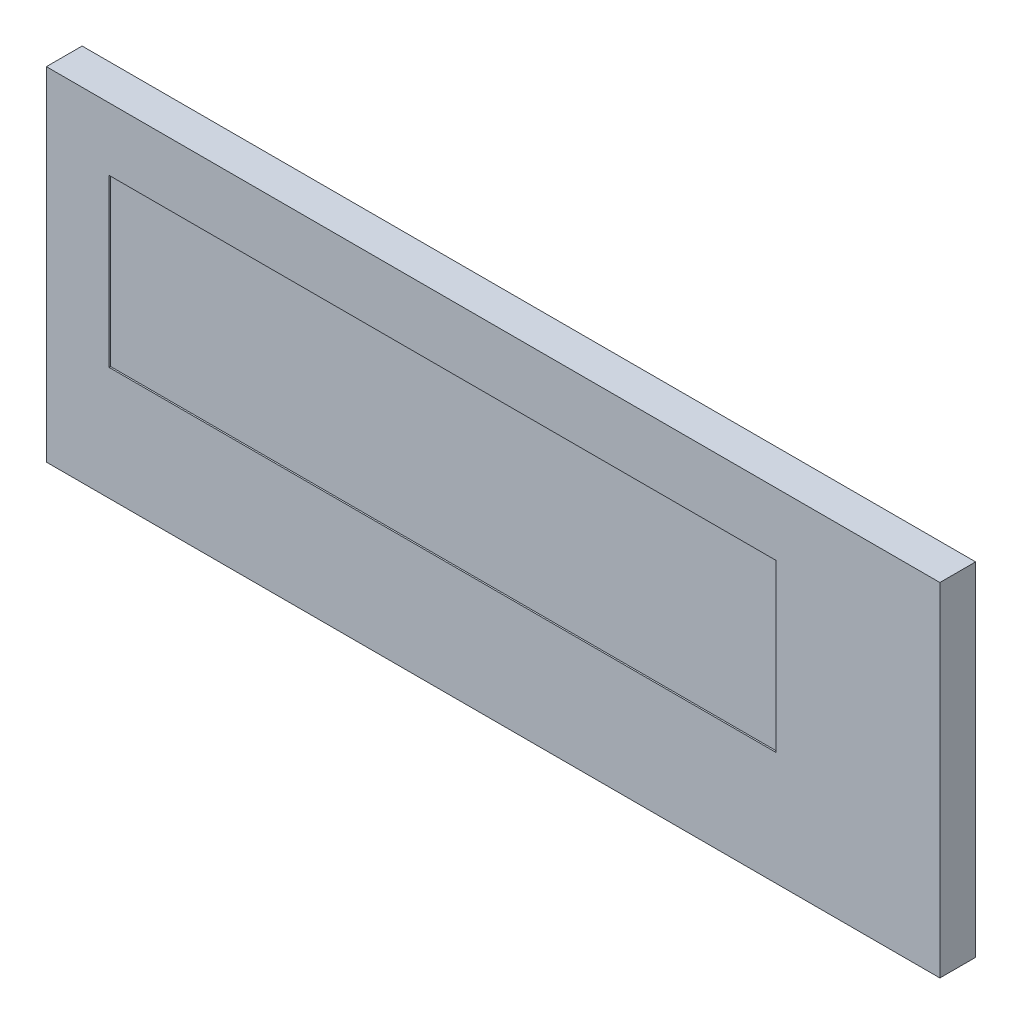
from build123d import *

# Parameters (mm, degrees)
SKETCH_1_W      = 30
SKETCH_1_H      = 11.5
SKETCH_1_W_2    = 22.384
SKETCH_1_H_2    = 5.584
EXTRUDE_2_DEPTH = 1.2
SKETCH_1_6_W    = 22.384
SKETCH_1_6_H    = 5.584
EXTRUDE_4_DEPTH = 1.15


with BuildPart() as part:
    # 草图1 → 凸台-拉伸2 (new body)
    with BuildSketch(Plane.XY):
        with Locations((1.7, -0.85)):
            Rectangle(SKETCH_1_W, SKETCH_1_H)
        Rectangle(SKETCH_1_W_2, SKETCH_1_H_2, mode=Mode.SUBTRACT)
    extrude(amount=EXTRUDE_2_DEPTH)

    # 草图1<6> → 凸台-拉伸4 (add)
    with BuildSketch(Plane.XY):
        Rectangle(SKETCH_1_6_W, SKETCH_1_6_H)
    extrude(amount=EXTRUDE_4_DEPTH)


solid = part.part
